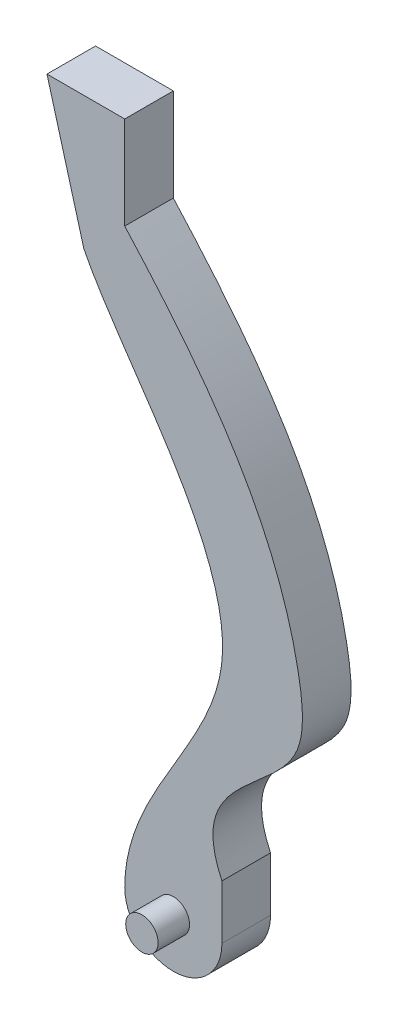
from build123d import *

# Parameters (mm, degrees)
BOSS_EXTRUDE1_DEPTH = 7.5
SKETCH6_R           = 5
BOSS_EXTRUDE2_DEPTH = 17.2


with BuildPart() as part:
    # Sketch2 → Boss-Extrude1 (new body, symmetric)
    with BuildSketch(Plane.XY):
        with BuildLine():
            Line((15, 0), (15, 16.68))
            add(Edge.make_bspline(
                [(15, 16.68), (3.450972579, 41.205169587), (42.592449362, 50.153261049), (36.123643096, 115.709280279), (9.335570979, 149.750442519), (-15, 176.722477056)],
                knots=[0, 0, 0, 0, 0.285986581, 0.402946003, 1, 1, 1, 1], degree=3))
            Line((-15, 176.722477056), (-15, 205.366233563))
            Line((-15, 205.366233563), (-39.002947465, 205.366233563))
            Line((-39.002947465, 205.366233563), (-27.618689918, 164.349947493))
            add(Edge.make_bspline(
                [(-27.618689918, 164.349947493), (-15.961544484, 140.960070013), (45.909256626, 77.600227818), (-14.865577471, 27.656075209), (-15, 0)],
                knots=[0, 0, 0, 0, 0.549643329, 1, 1, 1, 1], degree=3))
            ThreePointArc((-15, 0), (0, -15), (15, 0))
        make_face()
    extrude(amount=BOSS_EXTRUDE1_DEPTH, both=True)

    # Sketch6 → Boss-Extrude2 (add, symmetric)
    with BuildSketch(Plane.XY):
        Circle(SKETCH6_R)
    extrude(amount=BOSS_EXTRUDE2_DEPTH, both=True)


solid = part.part
